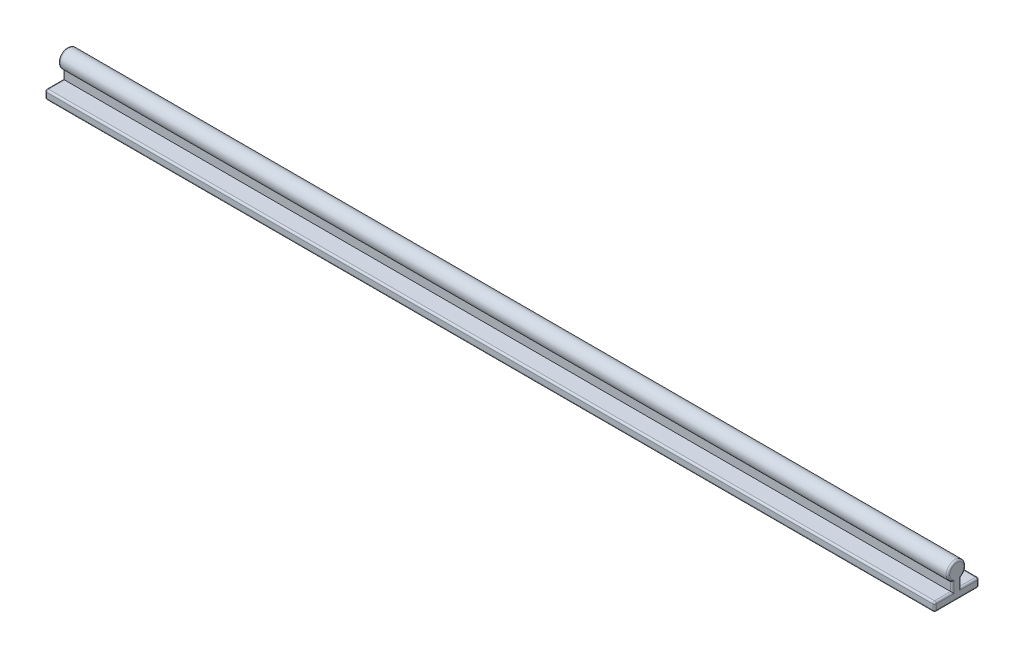
from build123d import *

# Parameters (mm, degrees)
BOSS_EXTRUDE1_DEPTH = 500
FILLET1_R           = 2


with BuildPart() as part:
    # Sketch2 → Boss-Extrude1 (new body, symmetric)
    with BuildSketch(Plane(origin=(0, 0, 0), x_dir=(0, 0, -1), z_dir=(1, 0, 0))):
        with BuildLine():
            Line((25, 0), (-25, 0))
            Line((-25, 0), (-25, 10))
            Line((-25, 10), (-5, 10))
            Line((-5, 10), (-5, 20))
            ThreePointArc((-5, 20), (0, 38.660254038), (5, 20))
            Line((5, 20), (5, 10))
            Line((5, 10), (25, 10))
            Line((25, 10), (25, 0))
        make_face()
    extrude(amount=BOSS_EXTRUDE1_DEPTH, both=True)

    # Fillet1
    fillet1_edges = [part.edges().sort_by_distance(p)[0] for p in [
        (500, 38.660254038, 0),
        (-500, 15, -5),
        (-500, 10, -15),
        (500, 15, 5),
        (0, 10, -25),
        (0, 0, -25),
        (0, 0, 25),
        (0, 10, 25),
        (500, 10, 15),
        (500, 5, 25),
        (500, 0, 0),
        (500, 5, -25),
        (500, 10, -15),
        (500, 15, -5),
        (-500, 5, -25),
        (-500, 0, 0),
        (-500, 5, 25),
        (-500, 10, 15),
        (-500, 15, 5),
        (-500, 38.660254038, 0),
    ]]
    fillet(fillet1_edges, radius=FILLET1_R)


solid = part.part
